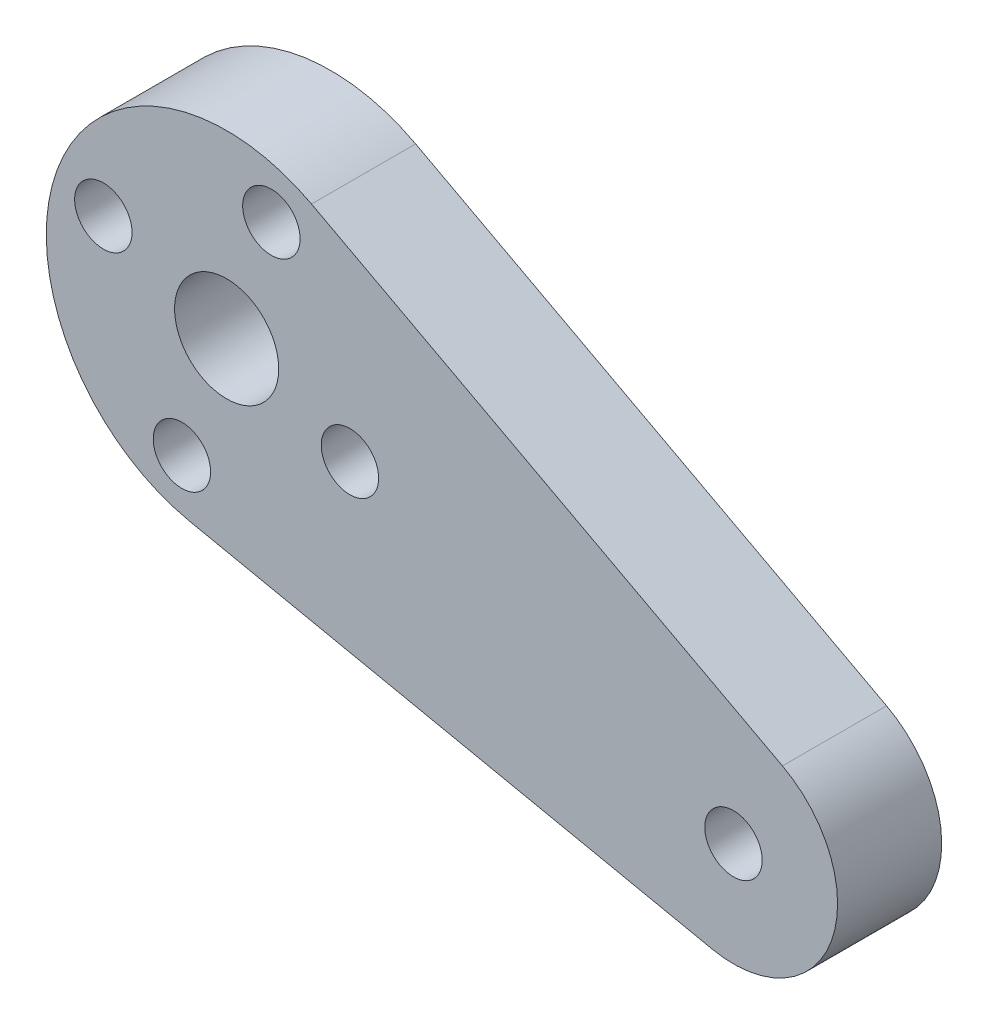
from build123d import *

# Parameters (mm, degrees)
SKETCH4_R           = 3.175
SKETCH4_R_2         = 1.75
BOSS_EXTRUDE1_DEPTH = 6.35


with BuildPart() as part:
    # Sketch4 → Boss-Extrude1 (new body)
    with BuildSketch(Plane.XY):
        with BuildLine():
            Line((43.977135669, 255.932866189), (75.839955751, 249.270355141))
            ThreePointArc((75.839955751, 249.270355141), (83.108950302, 253.320349798), (80.127586616, 261.089018222))
            Line((80.127586616, 261.089018222), (51.40452772, 276.406140819))
            ThreePointArc((51.40452772, 276.406140819), (35.887988835, 270.451395034), (43.977135669, 255.932866189))
        make_face()
        with Locations((46.228541785, 266.7)):
            Circle(SKETCH4_R, mode=Mode.SUBTRACT)
        with Locations((53.74894393, 263.971712703)):
            Circle(SKETCH4_R_2, mode=Mode.SUBTRACT)
        with Locations((77.139631099, 255.485927841)):
            Circle(SKETCH4_R_2, mode=Mode.SUBTRACT)
        with Locations((43.500254487, 259.179597855)):
            Circle(SKETCH4_R_2, mode=Mode.SUBTRACT)
        with Locations((38.708139639, 269.428287297)):
            Circle(SKETCH4_R_2, mode=Mode.SUBTRACT)
        with Locations((48.956829082, 274.220402145)):
            Circle(SKETCH4_R_2, mode=Mode.SUBTRACT)
    extrude(amount=BOSS_EXTRUDE1_DEPTH)


solid = part.part
